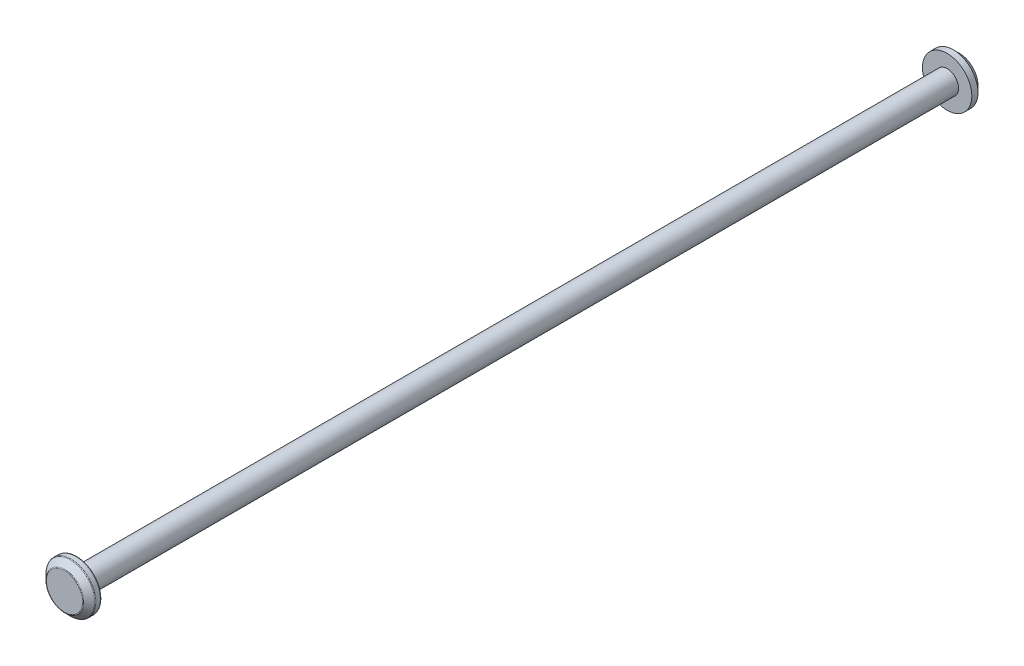
from build123d import *

# Parameters (mm, degrees)
SKETCH1_R           = 0.925
BOSS_EXTRUDE1_DEPTH = 35.25
SKETCH2_R           = 2
BOSS_EXTRUDE2_DEPTH = 1
CHAMFER1_SIZE       = 0.5
FILLET1_R           = 0.1
SCALE1_SCALE        = 5


with BuildPart() as part:
    # Sketch1 → Boss-Extrude1 (new body)
    with BuildSketch(Plane.XY):
        Circle(SKETCH1_R)
    extrude(amount=BOSS_EXTRUDE1_DEPTH)

    # Sketch2 → Boss-Extrude2 (add)
    with BuildSketch(Plane.XY.offset(35.25)):
        Circle(SKETCH2_R)
    extrude(amount=BOSS_EXTRUDE2_DEPTH)

    # Chamfer1
    chamfer1_edges = [part.edges().sort_by_distance(p)[0] for p in [
        (-2, 0, 36.25),
    ]]
    chamfer(chamfer1_edges, length=CHAMFER1_SIZE)

    # Mirror1: part across plane


with BuildPart() as part_1:
    add(part.part)
    add(part.part.mirror(Plane.XY))

    # Fillet1
    fillet1_edges = [part_1.edges().sort_by_distance(p)[0] for p in [
        (-1.5, 0, 36.25),
        (-2, 0, 35.75),
        (-0.925, 0, 35.25),
        (-2, 0, 35.25),
    ]]
    fillet(fillet1_edges, radius=FILLET1_R)


with BuildPart() as part_2:
    # Scale1: scaled about (-2.8e-08, 0, -0.003118898)
    add(part_1.part.scale(SCALE1_SCALE).moved(Location((1.12e-07, 0, 0.012475592))))


solid = part_2.part
